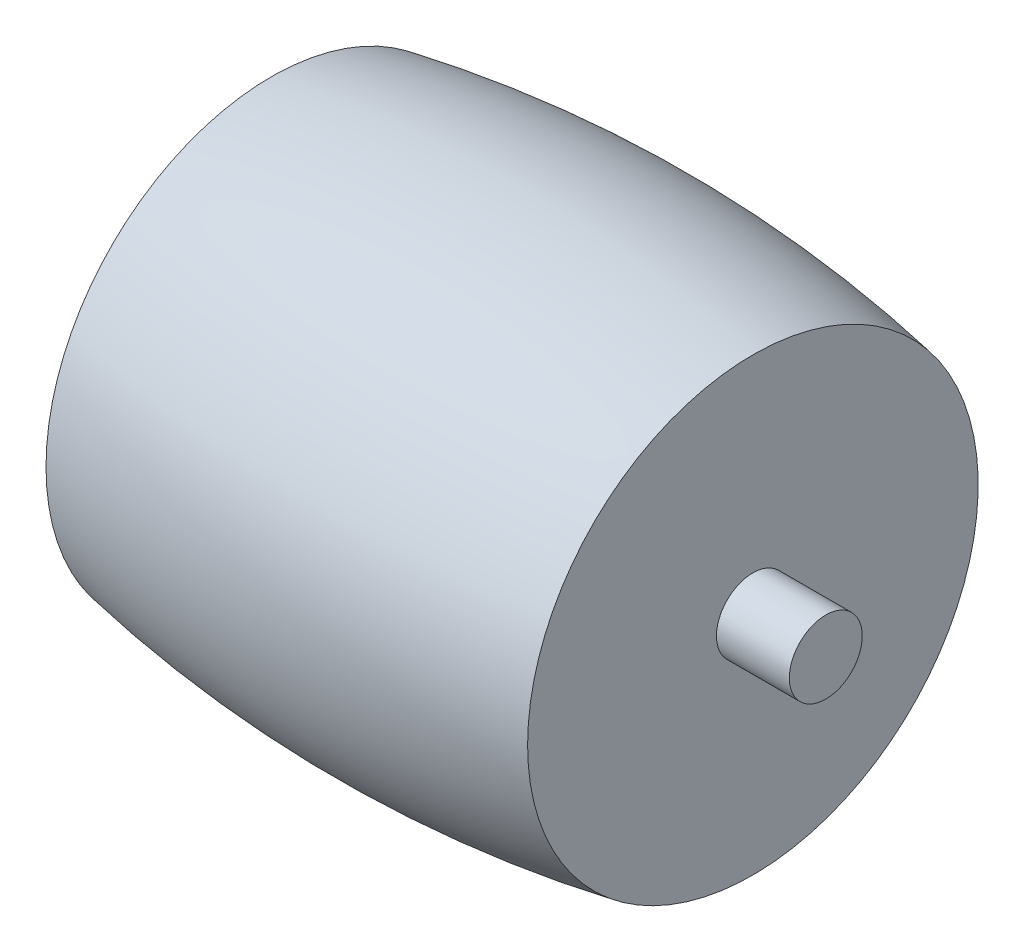
from build123d import *


with BuildPart() as part:
    # Sketch1 → Revolve1 (revolve)
    with BuildSketch(Plane.XY):
        with BuildLine():
            Line((9.25, 50.154137417), (9.25, 42.9))
            Line((9.25, 42.9), (12.05, 42.9))
            Line((12.05, 42.9), (12.05, 41.5))
            Line((12.05, 41.5), (9.25, 41.5))
            Line((9.25, 41.5), (-9.25, 41.5))
            Line((-9.25, 41.5), (-12.05, 41.5))
            Line((-12.05, 41.5), (-12.05, 42.9))
            Line((-12.05, 42.9), (-9.25, 42.9))
            Line((-9.25, 42.9), (-9.25, 50.154137417))
            ThreePointArc((-9.25, 50.154137417), (0, 51), (9.25, 50.154137417))
        make_face()
    revolve(axis=Axis((-9.25, 41.5, 0), (1, 0, 0)))


solid = part.part
